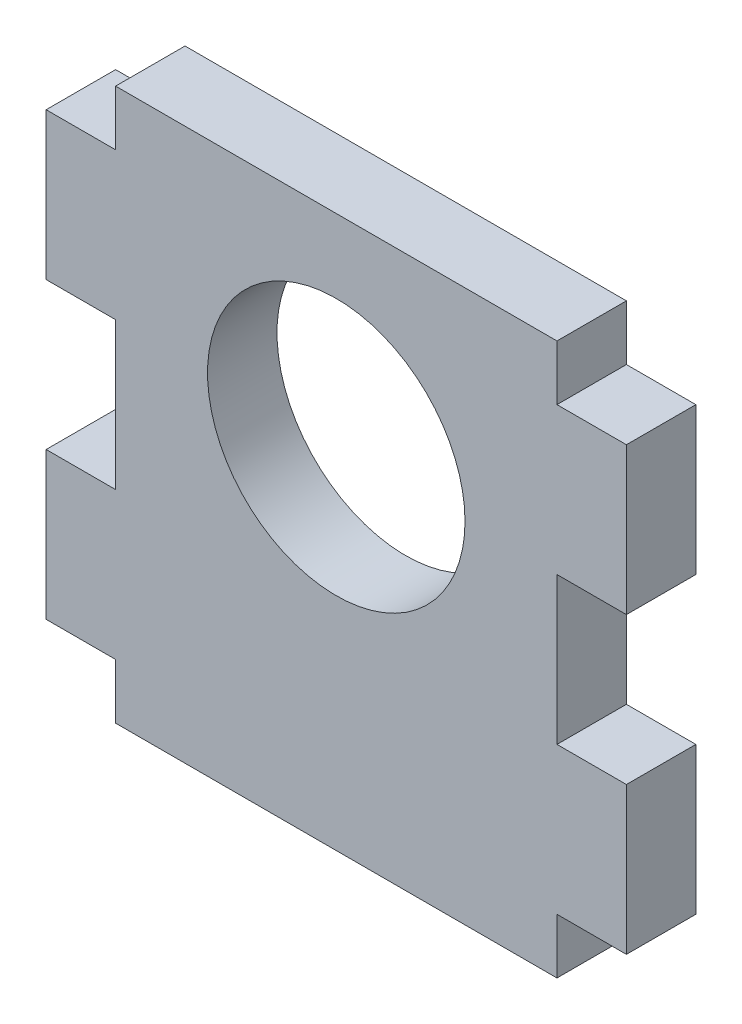
from build123d import *

# Parameters (mm, degrees)
SKETCH1_R           = 11.1125
BOSS_EXTRUDE1_DEPTH = 5.9944
SKETCH2_W           = 38.1
SKETCH2_H           = 1.5875
CUT_EXTRUDE1_DEPTH  = 6.9944


with BuildPart() as part:
    # Sketch1 → Boss-Extrude1 (new body)
    with BuildSketch(Plane.XY):
        Polygon((19.05, 19.05), (-19.05, 19.05), (-19.05, 12.7), (-25.0444, 12.7), (-25.0444, 0), (-19.05, 0), (-19.05, -12.7), (-25.0444, -12.7), (-25.0444, -25.4), (-19.05, -25.4), (-19.05, -31.75), (19.05, -31.75), (19.05, -25.4), (25.0444, -25.4), (25.0444, -12.7), (19.05, -12.7), (19.05, 0), (25.0444, 0), (25.0444, 12.7), (19.05, 12.7), align=None)
        Circle(SKETCH1_R, mode=Mode.SUBTRACT)
    extrude(amount=BOSS_EXTRUDE1_DEPTH)

    # Sketch2 → Cut-Extrude1 (cut, through all)
    with BuildSketch(Plane.XY.offset(5.9944)):
        with Locations((0, -30.95625)):
            Rectangle(SKETCH2_W, SKETCH2_H)
        with Locations((0, 18.25625)):
            Rectangle(SKETCH2_W, SKETCH2_H)
    extrude(amount=-CUT_EXTRUDE1_DEPTH, mode=Mode.SUBTRACT)


solid = part.part
